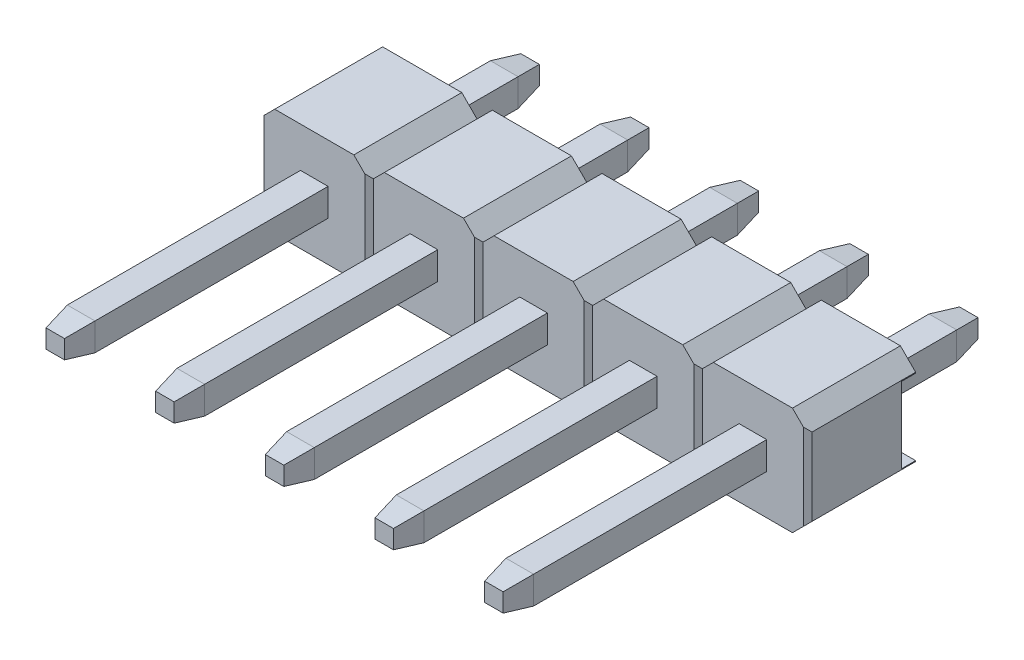
from build123d import *
from OCP.BRepFilletAPI import BRepFilletAPI_MakeChamfer

# Parameters (mm, degrees)
EXTRUDE1_DEPTH          = 1.25
CUT_EXTRUDE3_DEPTH      = 3.176671771
LPATTERN4_COUNT         = 5
LPATTERN4_PITCH         = 2.54
CUT_EXTRUDE1_DEPTH      = 12.565893826
CUT_EXTRUDE1_DEPTH_BACK = 12.565893826
SKETCH2_W               = 1.752893218
SKETCH2_H               = 0.33
SKETCH3_W               = 11
SKETCH3_H               = 0.64
EXTRUDE_THIN1_DEPTH     = 0.32
LPATTERN5_COUNT         = 5
LPATTERN5_PITCH         = 2.54
CHAMFER2_SIZE           = 0.6
CHAMFER2_SIZE2          = 0.105796188


with BuildPart() as part:
    # Sketch1 → Extrude1 (new, symmetric)
    with BuildSketch(Plane.XY):
        Polygon((-1.27, 0.896446609), (-0.916446609, 1.25), (0.916446609, 1.25), (1.27, 0.896446609), (1.27, -0.896446609), (0.916446609, -1.25), (-0.916446609, -1.25), (-1.27, -0.896446609), align=None)
    extrude1 = extrude(amount=EXTRUDE1_DEPTH, both=True)

    # Sketch4 → Cut-Extrude3 (cut, symmetric)
    with BuildSketch(Plane(origin=(0, 0, 0), x_dir=(1, 0, 0), z_dir=(0, 1, 0))):
        Polygon((-1.27, -1.15), (-1.17, -1.25), (-1.27, -1.25), align=None)
        Polygon((1.17, -1.25), (1.27, -1.15), (1.27, -1.25), align=None)
    cut_extrude3 = extrude(amount=CUT_EXTRUDE3_DEPTH, both=True, mode=Mode.SUBTRACT)

    # LPattern4: Extrude1, Cut-Extrude3 ×5
    with Locations(*[(-i * LPATTERN4_PITCH, 0, 0) for i in range(1, LPATTERN4_COUNT)]):
        add(extrude1)
        add(cut_extrude3, mode=Mode.SUBTRACT)

    # Sketch2 → Cut-Extrude1 (cut, two sides: drawn at the far end of the back side and taken through both)
    with BuildSketch(Plane(origin=(0, 0, 0), x_dir=(0, -1, 0), z_dir=(1, 0, 0)).offset(-CUT_EXTRUDE1_DEPTH_BACK)):
        with Locations((0, 1.085)):
            Rectangle(SKETCH2_W, SKETCH2_H)
    extrude(amount=CUT_EXTRUDE1_DEPTH + CUT_EXTRUDE1_DEPTH_BACK, mode=Mode.SUBTRACT)

    # Sketch3 → Extrude-Thin1 (add, symmetric)
    with BuildSketch(Plane(origin=(0, 0, 0), x_dir=(0, 0, -1), z_dir=(1, 0, 0))):
        with Locations((-1.75, 0)):
            Rectangle(SKETCH3_W, SKETCH3_H)
    extrude_thin1 = extrude(amount=EXTRUDE_THIN1_DEPTH, both=True)

    # LPattern5: Extrude-Thin1 ×5
    with Locations(*[(-i * LPATTERN5_PITCH, 0, 0) for i in range(1, LPATTERN5_COUNT)]):
        add(extrude_thin1)

    # Chamfer2: one chamfer whose edges measure the first distance from different faces: ONE call of the kernel's chamfer builder (chamfer() names one face for all edges)
    chamfer2_edges_1 = [part.edges().sort_by_distance(p)[0] for p in [
        (0.32, 0, 7.25),
    ]]
    chamfer2_side_1 = [part.faces().sort_by_distance(p)[0] for p in [
        (0.32, 0, 4.25),
    ]]
    chamfer2_edges_2 = [part.edges().sort_by_distance(p)[0] for p in [
        (0, -0.32, 7.25),
    ]]
    chamfer2_side_2 = [part.faces().sort_by_distance(p)[0] for p in [
        (0, -0.32, 4.25),
    ]]
    chamfer2_edges_3 = [part.edges().sort_by_distance(p)[0] for p in [
        (-0.32, 0, 7.25),
    ]]
    chamfer2_side_3 = [part.faces().sort_by_distance(p)[0] for p in [
        (-0.32, 0, 4.25),
    ]]
    chamfer2_edges_4 = [part.edges().sort_by_distance(p)[0] for p in [
        (0, 0.32, 7.25),
    ]]
    chamfer2_side_4 = [part.faces().sort_by_distance(p)[0] for p in [
        (0, 0.32, 4.25),
    ]]
    chamfer2_edges_5 = [part.edges().sort_by_distance(p)[0] for p in [
        (0.32, 0, -3.75),
    ]]
    chamfer2_side_5 = [part.faces().sort_by_distance(p)[0] for p in [
        (0.32, 0, -2.335),
    ]]
    chamfer2_edges_6 = [part.edges().sort_by_distance(p)[0] for p in [
        (-0.32, 0, -3.75),
    ]]
    chamfer2_side_6 = [part.faces().sort_by_distance(p)[0] for p in [
        (-0.32, 0, -2.335),
    ]]
    chamfer2_edges_7 = [part.edges().sort_by_distance(p)[0] for p in [
        (-4.76, 0, -3.75),
    ]]
    chamfer2_side_7 = [part.faces().sort_by_distance(p)[0] for p in [
        (-4.76, 0, -2.335),
    ]]
    chamfer2_edges_8 = [part.edges().sort_by_distance(p)[0] for p in [
        (-5.4, 0, -3.75),
    ]]
    chamfer2_side_8 = [part.faces().sort_by_distance(p)[0] for p in [
        (-5.4, 0, -2.335),
    ]]
    chamfer2_edges_9 = [part.edges().sort_by_distance(p)[0] for p in [
        (-2.22, 0, -3.75),
    ]]
    chamfer2_side_9 = [part.faces().sort_by_distance(p)[0] for p in [
        (-2.22, 0, -2.335),
    ]]
    chamfer2_edges_10 = [part.edges().sort_by_distance(p)[0] for p in [
        (-2.86, 0, -3.75),
    ]]
    chamfer2_side_10 = [part.faces().sort_by_distance(p)[0] for p in [
        (-2.86, 0, -2.335),
    ]]
    chamfer2_edges_11 = [part.edges().sort_by_distance(p)[0] for p in [
        (-2.22, 0, 7.25),
    ]]
    chamfer2_side_11 = [part.faces().sort_by_distance(p)[0] for p in [
        (-2.22, 0, 4.25),
    ]]
    chamfer2_edges_12 = [part.edges().sort_by_distance(p)[0] for p in [
        (-2.54, -0.32, 7.25),
    ]]
    chamfer2_side_12 = [part.faces().sort_by_distance(p)[0] for p in [
        (-2.54, -0.32, 4.25),
    ]]
    chamfer2_edges_13 = [part.edges().sort_by_distance(p)[0] for p in [
        (-2.86, 0, 7.25),
    ]]
    chamfer2_side_13 = [part.faces().sort_by_distance(p)[0] for p in [
        (-2.86, 0, 4.25),
    ]]
    chamfer2_edges_14 = [part.edges().sort_by_distance(p)[0] for p in [
        (-2.54, 0.32, 7.25),
    ]]
    chamfer2_side_14 = [part.faces().sort_by_distance(p)[0] for p in [
        (-2.54, 0.32, 4.25),
    ]]
    chamfer2_edges_15 = [part.edges().sort_by_distance(p)[0] for p in [
        (-4.76, 0, 7.25),
    ]]
    chamfer2_side_15 = [part.faces().sort_by_distance(p)[0] for p in [
        (-4.76, 0, 4.25),
    ]]
    chamfer2_edges_16 = [part.edges().sort_by_distance(p)[0] for p in [
        (-5.08, -0.32, 7.25),
    ]]
    chamfer2_side_16 = [part.faces().sort_by_distance(p)[0] for p in [
        (-5.08, -0.32, 4.25),
    ]]
    chamfer2_edges_17 = [part.edges().sort_by_distance(p)[0] for p in [
        (-5.4, 0, 7.25),
    ]]
    chamfer2_side_17 = [part.faces().sort_by_distance(p)[0] for p in [
        (-5.4, 0, 4.25),
    ]]
    chamfer2_edges_18 = [part.edges().sort_by_distance(p)[0] for p in [
        (-5.08, 0.32, 7.25),
    ]]
    chamfer2_side_18 = [part.faces().sort_by_distance(p)[0] for p in [
        (-5.08, 0.32, 4.25),
    ]]
    chamfer2_edges_19 = [part.edges().sort_by_distance(p)[0] for p in [
        (-2.54, 0.32, -3.75),
    ]]
    chamfer2_side_19 = [part.faces().sort_by_distance(p)[0] for p in [
        (-2.54, 0.32, -2.335),
    ]]
    chamfer2_edges_20 = [part.edges().sort_by_distance(p)[0] for p in [
        (-2.54, -0.32, -3.75),
    ]]
    chamfer2_side_20 = [part.faces().sort_by_distance(p)[0] for p in [
        (-2.54, -0.32, -2.335),
    ]]
    chamfer2_edges_21 = [part.edges().sort_by_distance(p)[0] for p in [
        (0, 0.32, -3.75),
    ]]
    chamfer2_side_21 = [part.faces().sort_by_distance(p)[0] for p in [
        (0, 0.32, -2.335),
    ]]
    chamfer2_edges_22 = [part.edges().sort_by_distance(p)[0] for p in [
        (0, -0.32, -3.75),
    ]]
    chamfer2_side_22 = [part.faces().sort_by_distance(p)[0] for p in [
        (0, -0.32, -2.335),
    ]]
    chamfer2_edges_23 = [part.edges().sort_by_distance(p)[0] for p in [
        (-9.84, 0, -3.75),
    ]]
    chamfer2_side_23 = [part.faces().sort_by_distance(p)[0] for p in [
        (-9.84, 0, -2.335),
    ]]
    chamfer2_edges_24 = [part.edges().sort_by_distance(p)[0] for p in [
        (-10.16, 0.32, -3.75),
    ]]
    chamfer2_side_24 = [part.faces().sort_by_distance(p)[0] for p in [
        (-10.16, 0.32, -2.335),
    ]]
    chamfer2_edges_25 = [part.edges().sort_by_distance(p)[0] for p in [
        (-10.48, 0, -3.75),
    ]]
    chamfer2_side_25 = [part.faces().sort_by_distance(p)[0] for p in [
        (-10.48, 0, -2.335),
    ]]
    chamfer2_edges_26 = [part.edges().sort_by_distance(p)[0] for p in [
        (-10.16, -0.32, -3.75),
    ]]
    chamfer2_side_26 = [part.faces().sort_by_distance(p)[0] for p in [
        (-10.16, -0.32, -2.335),
    ]]
    chamfer2_edges_27 = [part.edges().sort_by_distance(p)[0] for p in [
        (-7.3, 0, -3.75),
    ]]
    chamfer2_side_27 = [part.faces().sort_by_distance(p)[0] for p in [
        (-7.3, 0, -2.335),
    ]]
    chamfer2_edges_28 = [part.edges().sort_by_distance(p)[0] for p in [
        (-7.62, 0.32, -3.75),
    ]]
    chamfer2_side_28 = [part.faces().sort_by_distance(p)[0] for p in [
        (-7.62, 0.32, -2.335),
    ]]
    chamfer2_edges_29 = [part.edges().sort_by_distance(p)[0] for p in [
        (-7.94, 0, -3.75),
    ]]
    chamfer2_side_29 = [part.faces().sort_by_distance(p)[0] for p in [
        (-7.94, 0, -2.335),
    ]]
    chamfer2_edges_30 = [part.edges().sort_by_distance(p)[0] for p in [
        (-7.62, -0.32, -3.75),
    ]]
    chamfer2_side_30 = [part.faces().sort_by_distance(p)[0] for p in [
        (-7.62, -0.32, -2.335),
    ]]
    chamfer2_edges_31 = [part.edges().sort_by_distance(p)[0] for p in [
        (-5.08, 0.32, -3.75),
    ]]
    chamfer2_side_31 = [part.faces().sort_by_distance(p)[0] for p in [
        (-5.08, 0.32, -2.335),
    ]]
    chamfer2_edges_32 = [part.edges().sort_by_distance(p)[0] for p in [
        (-5.08, -0.32, -3.75),
    ]]
    chamfer2_side_32 = [part.faces().sort_by_distance(p)[0] for p in [
        (-5.08, -0.32, -2.335),
    ]]
    chamfer2_edges_33 = [part.edges().sort_by_distance(p)[0] for p in [
        (-9.84, 0, 7.25),
    ]]
    chamfer2_side_33 = [part.faces().sort_by_distance(p)[0] for p in [
        (-9.84, 0, 4.25),
    ]]
    chamfer2_edges_34 = [part.edges().sort_by_distance(p)[0] for p in [
        (-10.16, -0.32, 7.25),
    ]]
    chamfer2_side_34 = [part.faces().sort_by_distance(p)[0] for p in [
        (-10.16, -0.32, 4.25),
    ]]
    chamfer2_edges_35 = [part.edges().sort_by_distance(p)[0] for p in [
        (-10.48, 0, 7.25),
    ]]
    chamfer2_side_35 = [part.faces().sort_by_distance(p)[0] for p in [
        (-10.48, 0, 4.25),
    ]]
    chamfer2_edges_36 = [part.edges().sort_by_distance(p)[0] for p in [
        (-10.16, 0.32, 7.25),
    ]]
    chamfer2_side_36 = [part.faces().sort_by_distance(p)[0] for p in [
        (-10.16, 0.32, 4.25),
    ]]
    chamfer2_edges_37 = [part.edges().sort_by_distance(p)[0] for p in [
        (-7.3, 0, 7.25),
    ]]
    chamfer2_side_37 = [part.faces().sort_by_distance(p)[0] for p in [
        (-7.3, 0, 4.25),
    ]]
    chamfer2_edges_38 = [part.edges().sort_by_distance(p)[0] for p in [
        (-7.62, -0.32, 7.25),
    ]]
    chamfer2_side_38 = [part.faces().sort_by_distance(p)[0] for p in [
        (-7.62, -0.32, 4.25),
    ]]
    chamfer2_edges_39 = [part.edges().sort_by_distance(p)[0] for p in [
        (-7.94, 0, 7.25),
    ]]
    chamfer2_side_39 = [part.faces().sort_by_distance(p)[0] for p in [
        (-7.94, 0, 4.25),
    ]]
    chamfer2_edges_40 = [part.edges().sort_by_distance(p)[0] for p in [
        (-7.62, 0.32, 7.25),
    ]]
    chamfer2_side_40 = [part.faces().sort_by_distance(p)[0] for p in [
        (-7.62, 0.32, 4.25),
    ]]
    chamfer2 = BRepFilletAPI_MakeChamfer(part.part.solid().wrapped)
    for e in chamfer2_edges_1:
        chamfer2.Add(CHAMFER2_SIZE, CHAMFER2_SIZE2, e.wrapped, chamfer2_side_1[0].wrapped)  # the first distance lies on this face
    for e in chamfer2_edges_2:
        chamfer2.Add(CHAMFER2_SIZE, CHAMFER2_SIZE2, e.wrapped, chamfer2_side_2[0].wrapped)  # the first distance lies on this face
    for e in chamfer2_edges_3:
        chamfer2.Add(CHAMFER2_SIZE, CHAMFER2_SIZE2, e.wrapped, chamfer2_side_3[0].wrapped)  # the first distance lies on this face
    for e in chamfer2_edges_4:
        chamfer2.Add(CHAMFER2_SIZE, CHAMFER2_SIZE2, e.wrapped, chamfer2_side_4[0].wrapped)  # the first distance lies on this face
    for e in chamfer2_edges_5:
        chamfer2.Add(CHAMFER2_SIZE, CHAMFER2_SIZE2, e.wrapped, chamfer2_side_5[0].wrapped)  # the first distance lies on this face
    for e in chamfer2_edges_6:
        chamfer2.Add(CHAMFER2_SIZE, CHAMFER2_SIZE2, e.wrapped, chamfer2_side_6[0].wrapped)  # the first distance lies on this face
    for e in chamfer2_edges_7:
        chamfer2.Add(CHAMFER2_SIZE, CHAMFER2_SIZE2, e.wrapped, chamfer2_side_7[0].wrapped)  # the first distance lies on this face
    for e in chamfer2_edges_8:
        chamfer2.Add(CHAMFER2_SIZE, CHAMFER2_SIZE2, e.wrapped, chamfer2_side_8[0].wrapped)  # the first distance lies on this face
    for e in chamfer2_edges_9:
        chamfer2.Add(CHAMFER2_SIZE, CHAMFER2_SIZE2, e.wrapped, chamfer2_side_9[0].wrapped)  # the first distance lies on this face
    for e in chamfer2_edges_10:
        chamfer2.Add(CHAMFER2_SIZE, CHAMFER2_SIZE2, e.wrapped, chamfer2_side_10[0].wrapped)  # the first distance lies on this face
    for e in chamfer2_edges_11:
        chamfer2.Add(CHAMFER2_SIZE, CHAMFER2_SIZE2, e.wrapped, chamfer2_side_11[0].wrapped)  # the first distance lies on this face
    for e in chamfer2_edges_12:
        chamfer2.Add(CHAMFER2_SIZE, CHAMFER2_SIZE2, e.wrapped, chamfer2_side_12[0].wrapped)  # the first distance lies on this face
    for e in chamfer2_edges_13:
        chamfer2.Add(CHAMFER2_SIZE, CHAMFER2_SIZE2, e.wrapped, chamfer2_side_13[0].wrapped)  # the first distance lies on this face
    for e in chamfer2_edges_14:
        chamfer2.Add(CHAMFER2_SIZE, CHAMFER2_SIZE2, e.wrapped, chamfer2_side_14[0].wrapped)  # the first distance lies on this face
    for e in chamfer2_edges_15:
        chamfer2.Add(CHAMFER2_SIZE, CHAMFER2_SIZE2, e.wrapped, chamfer2_side_15[0].wrapped)  # the first distance lies on this face
    for e in chamfer2_edges_16:
        chamfer2.Add(CHAMFER2_SIZE, CHAMFER2_SIZE2, e.wrapped, chamfer2_side_16[0].wrapped)  # the first distance lies on this face
    for e in chamfer2_edges_17:
        chamfer2.Add(CHAMFER2_SIZE, CHAMFER2_SIZE2, e.wrapped, chamfer2_side_17[0].wrapped)  # the first distance lies on this face
    for e in chamfer2_edges_18:
        chamfer2.Add(CHAMFER2_SIZE, CHAMFER2_SIZE2, e.wrapped, chamfer2_side_18[0].wrapped)  # the first distance lies on this face
    for e in chamfer2_edges_19:
        chamfer2.Add(CHAMFER2_SIZE, CHAMFER2_SIZE2, e.wrapped, chamfer2_side_19[0].wrapped)  # the first distance lies on this face
    for e in chamfer2_edges_20:
        chamfer2.Add(CHAMFER2_SIZE, CHAMFER2_SIZE2, e.wrapped, chamfer2_side_20[0].wrapped)  # the first distance lies on this face
    for e in chamfer2_edges_21:
        chamfer2.Add(CHAMFER2_SIZE, CHAMFER2_SIZE2, e.wrapped, chamfer2_side_21[0].wrapped)  # the first distance lies on this face
    for e in chamfer2_edges_22:
        chamfer2.Add(CHAMFER2_SIZE, CHAMFER2_SIZE2, e.wrapped, chamfer2_side_22[0].wrapped)  # the first distance lies on this face
    for e in chamfer2_edges_23:
        chamfer2.Add(CHAMFER2_SIZE, CHAMFER2_SIZE2, e.wrapped, chamfer2_side_23[0].wrapped)  # the first distance lies on this face
    for e in chamfer2_edges_24:
        chamfer2.Add(CHAMFER2_SIZE, CHAMFER2_SIZE2, e.wrapped, chamfer2_side_24[0].wrapped)  # the first distance lies on this face
    for e in chamfer2_edges_25:
        chamfer2.Add(CHAMFER2_SIZE, CHAMFER2_SIZE2, e.wrapped, chamfer2_side_25[0].wrapped)  # the first distance lies on this face
    for e in chamfer2_edges_26:
        chamfer2.Add(CHAMFER2_SIZE, CHAMFER2_SIZE2, e.wrapped, chamfer2_side_26[0].wrapped)  # the first distance lies on this face
    for e in chamfer2_edges_27:
        chamfer2.Add(CHAMFER2_SIZE, CHAMFER2_SIZE2, e.wrapped, chamfer2_side_27[0].wrapped)  # the first distance lies on this face
    for e in chamfer2_edges_28:
        chamfer2.Add(CHAMFER2_SIZE, CHAMFER2_SIZE2, e.wrapped, chamfer2_side_28[0].wrapped)  # the first distance lies on this face
    for e in chamfer2_edges_29:
        chamfer2.Add(CHAMFER2_SIZE, CHAMFER2_SIZE2, e.wrapped, chamfer2_side_29[0].wrapped)  # the first distance lies on this face
    for e in chamfer2_edges_30:
        chamfer2.Add(CHAMFER2_SIZE, CHAMFER2_SIZE2, e.wrapped, chamfer2_side_30[0].wrapped)  # the first distance lies on this face
    for e in chamfer2_edges_31:
        chamfer2.Add(CHAMFER2_SIZE, CHAMFER2_SIZE2, e.wrapped, chamfer2_side_31[0].wrapped)  # the first distance lies on this face
    for e in chamfer2_edges_32:
        chamfer2.Add(CHAMFER2_SIZE, CHAMFER2_SIZE2, e.wrapped, chamfer2_side_32[0].wrapped)  # the first distance lies on this face
    for e in chamfer2_edges_33:
        chamfer2.Add(CHAMFER2_SIZE, CHAMFER2_SIZE2, e.wrapped, chamfer2_side_33[0].wrapped)  # the first distance lies on this face
    for e in chamfer2_edges_34:
        chamfer2.Add(CHAMFER2_SIZE, CHAMFER2_SIZE2, e.wrapped, chamfer2_side_34[0].wrapped)  # the first distance lies on this face
    for e in chamfer2_edges_35:
        chamfer2.Add(CHAMFER2_SIZE, CHAMFER2_SIZE2, e.wrapped, chamfer2_side_35[0].wrapped)  # the first distance lies on this face
    for e in chamfer2_edges_36:
        chamfer2.Add(CHAMFER2_SIZE, CHAMFER2_SIZE2, e.wrapped, chamfer2_side_36[0].wrapped)  # the first distance lies on this face
    for e in chamfer2_edges_37:
        chamfer2.Add(CHAMFER2_SIZE, CHAMFER2_SIZE2, e.wrapped, chamfer2_side_37[0].wrapped)  # the first distance lies on this face
    for e in chamfer2_edges_38:
        chamfer2.Add(CHAMFER2_SIZE, CHAMFER2_SIZE2, e.wrapped, chamfer2_side_38[0].wrapped)  # the first distance lies on this face
    for e in chamfer2_edges_39:
        chamfer2.Add(CHAMFER2_SIZE, CHAMFER2_SIZE2, e.wrapped, chamfer2_side_39[0].wrapped)  # the first distance lies on this face
    for e in chamfer2_edges_40:
        chamfer2.Add(CHAMFER2_SIZE, CHAMFER2_SIZE2, e.wrapped, chamfer2_side_40[0].wrapped)  # the first distance lies on this face
    add(Compound.cast(chamfer2.Shape()), mode=Mode.REPLACE)


solid = part.part
